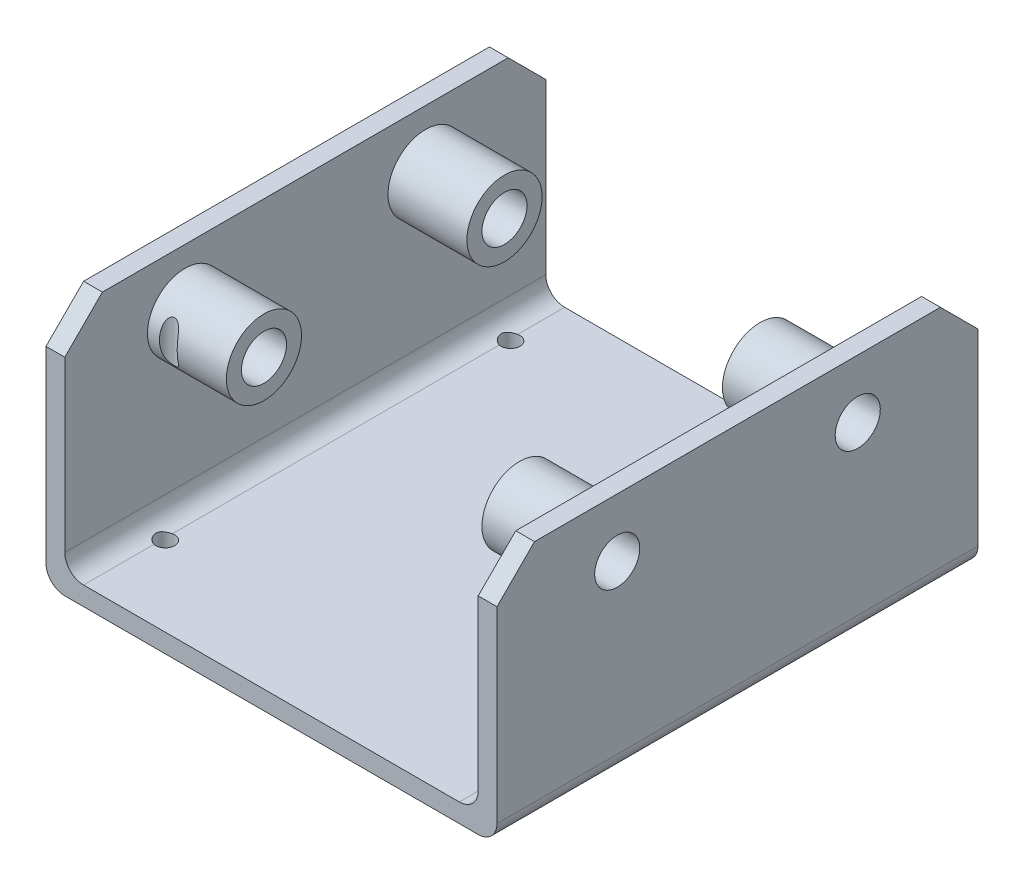
from build123d import *

# Parameters (mm, degrees)
BOSS_EXTRUDE1_DEPTH     = 128
FILLET1_R               = 5
CHAMFER1_SIZE           = 10
SKETCH3_R               = 6
CUT_EXTRUDE1_DEPTH      = 121
SKETCH5_R               = 10
BOSS_EXTRUDE2_DEPTH     = 21
SKETCH6_R               = 10
BOSS_EXTRUDE3_DEPTH     = 21
SKETCH7_R               = 6
CUT_EXTRUDE2_DEPTH      = 6
CUT_EXTRUDE2_DEPTH_BACK = 116
SKETCH8_R               = 2.5
CUT_EXTRUDE3_DEPTH      = 66


with BuildPart() as part:
    # Sketch2 → Boss-Extrude1 (new body)
    with BuildSketch(Plane.XY):
        Polygon((-55, 30), (-55, -30), (55, -30), (55, 30), (60, 30), (60, -35), (-60, -35), (-60, 30), align=None)
    extrude(amount=BOSS_EXTRUDE1_DEPTH)

    # Fillet1
    fillet1_edges = [part.edges().sort_by_distance(p)[0] for p in [
        (60, -35, 64),
        (-60, -35, 64),
        (-55, -30, 64),
        (55, -30, 64),
    ]]
    fillet(fillet1_edges, radius=FILLET1_R)

    # Chamfer1
    chamfer1_edges = [part.edges().sort_by_distance(p)[0] for p in [
        (-57.5, 30, 128),
        (57.5, 30, 128),
        (57.5, 30, 0),
        (-57.5, 30, 0),
    ]]
    chamfer(chamfer1_edges, length=CHAMFER1_SIZE)

    # Sketch3 → Cut-Extrude1 (cut, through all)
    with BuildSketch(Plane(origin=(60, 0, 0), x_dir=(0, 0, -1), z_dir=(1, 0, 0))):
        with Locations((-96, 14.48521638)):
            Circle(SKETCH3_R)
        with Locations((-32, 14.48521638)):
            Circle(SKETCH3_R)
    extrude(amount=-CUT_EXTRUDE1_DEPTH, mode=Mode.SUBTRACT)

    # Sketch5 → Boss-Extrude2 (add)
    with BuildSketch(Plane.ZY.offset(-55)):
        with Locations((32, 14.48521638)):
            Circle(SKETCH5_R)
        with Locations((96, 14.48521638)):
            Circle(SKETCH5_R)
    extrude(amount=BOSS_EXTRUDE2_DEPTH)

    # Sketch6 → Boss-Extrude3 (add)
    with BuildSketch(Plane(origin=(-55, 0, 0), x_dir=(0, 0, -1), z_dir=(1, 0, 0))):
        with Locations((-32, 14.48521638)):
            Circle(SKETCH6_R)
        with Locations((-96, 14.48521638)):
            Circle(SKETCH6_R)
    extrude(amount=BOSS_EXTRUDE3_DEPTH)

    # Sketch7 → Cut-Extrude2 (cut, two sides)
    with BuildSketch(Plane.ZY.offset(55)) as cut_extrude2_sk:
        with Locations((32, 14.48521638)):
            Circle(SKETCH7_R)
        with Locations((96, 14.48521638)):
            Circle(SKETCH7_R)
    extrude(amount=CUT_EXTRUDE2_DEPTH, mode=Mode.SUBTRACT)
    extrude(cut_extrude2_sk.sketch, amount=-CUT_EXTRUDE2_DEPTH_BACK, mode=Mode.SUBTRACT)

    # Sketch8 → Cut-Extrude3 (cut, through all)
    with BuildSketch(Plane.XZ.offset(35)):
        with Locations((49.450316968, 14.929077734)):
            Circle(SKETCH8_R)
        with Locations((-49.450316968, 14.929077734)):
            Circle(SKETCH8_R)
        with Locations((-49.450316968, 106.821296535)):
            Circle(SKETCH8_R)
        with Locations((49.450316968, 106.821296535)):
            Circle(SKETCH8_R)
    extrude(amount=-CUT_EXTRUDE3_DEPTH, mode=Mode.SUBTRACT)


solid = part.part
